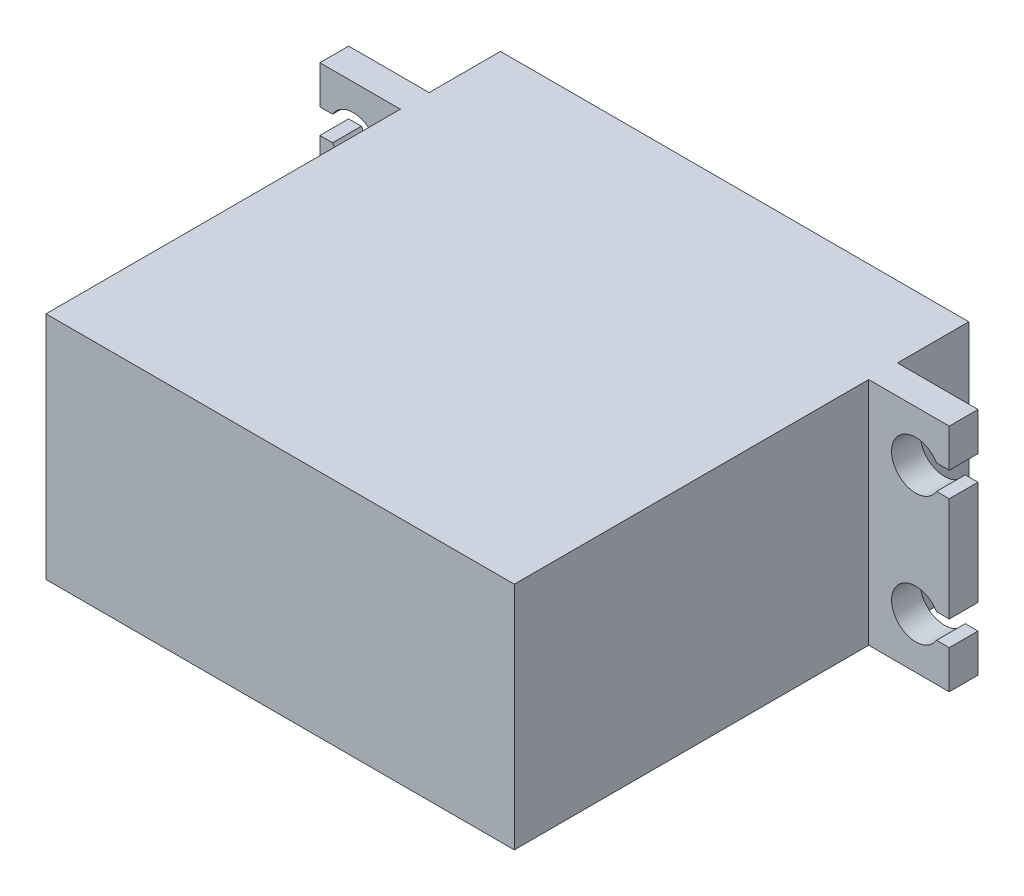
from build123d import *

# Parameters (mm, degrees)
SKETCH1_W                       = 40.7
SKETCH1_H                       = 39.5
BOSS_EXTRUDE1_DEPTH             = 10
SKETCH2_W                       = 2.5
SKETCH2_H                       = 20
BOSS_EXTRUDE2_DEPTH             = 7
BOSS_EXTRUDE5_DEPTH             = 0.5
CUT_EXTRUDE1_DEPTH              = 34.3
SKETCH4_R                       = 6.57
BOSS_EXTRUDE3_DEPTH             = 1.5
SKETCH5_R                       = 3
BOSS_EXTRUDE4_DEPTH             = 4.2
M3X0_5_TAPPED_HOLE1_D           = 2.5
M3X0_5_TAPPED_HOLE1_DEPTH       = 5
M3X0_5_TAPPED_HOLE1_CSINK_D     = 3.05
M3X0_5_TAPPED_HOLE1_CSINK_ANGLE = 90
M3X0_5_TAPPED_HOLE1_TIP         = 0.751075774


with BuildPart() as part:
    # Sketch1 → Boss-Extrude1 (new body, symmetric)
    with BuildSketch(Plane(origin=(0, 0, 0), x_dir=(1, 0, 0), z_dir=(0, 1, 0))):
        Rectangle(SKETCH1_W, SKETCH1_H)
    extrude(amount=BOSS_EXTRUDE1_DEPTH, both=True)

    # Sketch2 → Boss-Extrude2 (add)
    with BuildSketch(Plane(origin=(20.35, 0, 0), x_dir=(0, 0, -1), z_dir=(1, 0, 0))):
        with Locations((12.3, 0)):
            Rectangle(SKETCH2_W, SKETCH2_H)
    boss_extrude2 = extrude(amount=BOSS_EXTRUDE2_DEPTH)

    # Sketch9 → Boss-Extrude5 (add, symmetric)
    with BuildSketch(Plane(origin=(0, 0, 0), x_dir=(1, 0, 0), z_dir=(0, 1, 0))):
        Polygon((20.35, 13.55), (20.35, 14.65), (27.35, 13.55), align=None)
    boss_extrude5 = extrude(amount=BOSS_EXTRUDE5_DEPTH, both=True)

    # Mirror1: Boss-Extrude2, Boss-Extrude5 across plane
    add(boss_extrude2.mirror(Plane(origin=(0, 0, 0), x_dir=(0, 0, 1), z_dir=(1, 0, 0))))
    add(boss_extrude5.mirror(Plane(origin=(0, 0, 0), x_dir=(0, 0, 1), z_dir=(1, 0, 0))))

    # Sketch3 → Cut-Extrude1 (cut, through all)
    with BuildSketch(Plane(origin=(0, 0, -13.55), x_dir=(-1, 0, 0), z_dir=(0, 0, -1))):
        with BuildLine():
            Line((-26.243988636, 6.675), (-27.35, 6.675))
            Line((-27.35, 6.675), (-27.35, 4.525))
            Line((-27.35, 4.525), (-26.243988636, 4.525))
            ThreePointArc((-26.243988636, 4.525), (-22.34, 5.6), (-26.243988636, 6.675))
        make_face()
        with BuildLine():
            Line((26.243988636, 6.675), (27.35, 6.675))
            Line((27.35, 6.675), (27.35, 4.525))
            Line((27.35, 4.525), (26.243988636, 4.525))
            ThreePointArc((26.243988636, 4.525), (22.34, 5.6), (26.243988636, 6.675))
        make_face()
    cut_extrude1 = extrude(amount=-CUT_EXTRUDE1_DEPTH, mode=Mode.SUBTRACT)

    # Mirror2: Cut-Extrude1 across plane
    add(cut_extrude1.mirror(Plane.ZX), mode=Mode.SUBTRACT)

    # Sketch4 → Boss-Extrude3 (add)
    with BuildSketch(Plane(origin=(0, 0, -19.75), x_dir=(-1, 0, 0), z_dir=(0, 0, -1))):
        with Locations((-10.62, 0)):
            Circle(SKETCH4_R)
    extrude(amount=BOSS_EXTRUDE3_DEPTH)

    # Sketch5 → Boss-Extrude4 (add)
    with BuildSketch(Plane(origin=(0, 0, -21.25), x_dir=(-1, 0, 0), z_dir=(0, 0, -1))):
        with Locations((-10.62, 0)):
            Circle(SKETCH5_R)
    extrude(amount=BOSS_EXTRUDE4_DEPTH)

    # M3x0.5 Tapped Hole1
    with Locations(Plane(origin=(0, 0, -25.45), x_dir=(-1, 0, 0), z_dir=(0, 0, -1))):
        with Locations((-10.62, 0)):
            CounterSinkHole(M3X0_5_TAPPED_HOLE1_D / 2, M3X0_5_TAPPED_HOLE1_CSINK_D / 2, depth=M3X0_5_TAPPED_HOLE1_DEPTH, counter_sink_angle=M3X0_5_TAPPED_HOLE1_CSINK_ANGLE)
            with Locations((0, 0, -(M3X0_5_TAPPED_HOLE1_DEPTH + M3X0_5_TAPPED_HOLE1_TIP / 2))):  # 118° drill point
                Cone(0, M3X0_5_TAPPED_HOLE1_D / 2, M3X0_5_TAPPED_HOLE1_TIP, mode=Mode.SUBTRACT)


solid = part.part
